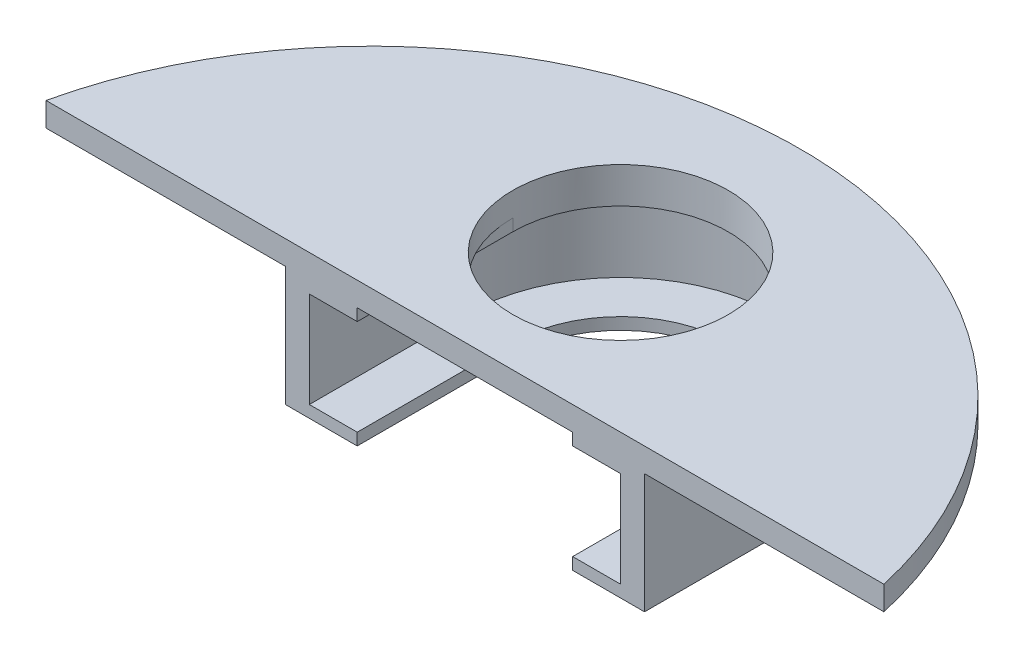
from build123d import *

# Parameters (mm, degrees)
SKETCH1_R           = 9
BOSS_EXTRUDE1_DEPTH = 2
BOSS_EXTRUDE3_DEPTH = 9
BOSS_EXTRUDE4_DEPTH = 1
BOSS_EXTRUDE5_START = -9
BOSS_EXTRUDE5_DEPTH = 1


with BuildPart() as part:
    # Sketch1 → Boss-Extrude1 (new body)
    with BuildSketch(Plane(origin=(0, 0, 0), x_dir=(1, 0, 0), z_dir=(0, 1, 0))):
        with BuildLine():
            Line((-35, -13), (35, -13))
            ThreePointArc((35, -13), (0, 15), (-35, -13))
        make_face()
        Circle(SKETCH1_R, mode=Mode.SUBTRACT)
    extrude(amount=BOSS_EXTRUDE1_DEPTH)

    # Sketch1_5 → Boss-Extrude3 (add)
    with BuildSketch(Plane(origin=(0, 0, 0), x_dir=(1, 0, 0), z_dir=(0, 1, 0))):
        with BuildLine():
            ThreePointArc((9.437961603, 11.658682635), (4.766399393, 12.662994302), (6.3e-08, 13))
            ThreePointArc((6.3e-08, 13), (9.192388178, 9.192388133), (13, 0))
            Line((13, 0), (13, -13))
            Line((13, -13), (15, -13))
            Line((15, -13), (15, 0))
            ThreePointArc((15, 0), (13.538268428, 6.458737336), (9.437961603, 11.658682635))
        make_face()
        with BuildLine():
            ThreePointArc((-9.437961603, 11.658682635), (-4.76639933, 12.662994311), (6.3e-08, 13))
            ThreePointArc((6.3e-08, 13), (4.766399393, 12.662994302), (9.437961603, 11.658682635))
            ThreePointArc((9.437961603, 11.658682635), (5.005984494, 14.140018361), (1.09e-07, 15))
            ThreePointArc((1.09e-07, 15), (-5.005984391, 14.140018397), (-9.437961603, 11.658682635))
        make_face()
        with BuildLine():
            Line((-13, -13), (-13, 0))
            ThreePointArc((-13, 0), (-9.192388133, 9.192388178), (6.3e-08, 13))
            ThreePointArc((6.3e-08, 13), (-4.76639933, 12.662994311), (-9.437961603, 11.658682635))
            ThreePointArc((-9.437961603, 11.658682635), (-13.538268428, 6.458737336), (-15, 0))
            Line((-15, 0), (-15, -13))
            Line((-15, -13), (-13, -13))
        make_face()
    extrude(amount=-BOSS_EXTRUDE3_DEPTH)

    # Sketch1_6 → Boss-Extrude4 (add)
    with BuildSketch(Plane(origin=(0, 0, 0), x_dir=(1, 0, 0), z_dir=(0, 1, 0))):
        with BuildLine():
            ThreePointArc((6.3e-08, 13), (-9.192388133, 9.192388178), (-13, 0))
            Line((-13, 0), (-13, -13))
            Line((-13, -13), (-9, -13))
            Line((-9, -13), (-9, 0))
            ThreePointArc((-9, 0), (0, 9), (9, 0))
            Line((9, 0), (9, -13))
            Line((9, -13), (13, -13))
            Line((13, -13), (13, 0))
            ThreePointArc((13, 0), (9.192388178, 9.192388133), (6.3e-08, 13))
        make_face()
    extrude(amount=-BOSS_EXTRUDE4_DEPTH)

    # Sketch1_7 → Boss-Extrude5 (add)
    with BuildSketch(Plane(origin=(0, 0, 0), x_dir=(1, 0, 0), z_dir=(0, 1, 0)).offset(BOSS_EXTRUDE5_START)):
        with BuildLine():
            Line((-13, -13), (-13, 0))
            ThreePointArc((-13, 0), (-9.192388133, 9.192388178), (6.3e-08, 13))
            ThreePointArc((6.3e-08, 13), (-4.76639933, 12.662994311), (-9.437961603, 11.658682635))
            ThreePointArc((-9.437961603, 11.658682635), (-13.538268428, 6.458737336), (-15, 0))
            Line((-15, 0), (-15, -13))
            Line((-15, -13), (-13, -13))
        make_face()
        with BuildLine():
            ThreePointArc((-9.437961603, 11.658682635), (-4.76639933, 12.662994311), (6.3e-08, 13))
            ThreePointArc((6.3e-08, 13), (4.766399393, 12.662994302), (9.437961603, 11.658682635))
            ThreePointArc((9.437961603, 11.658682635), (5.005984494, 14.140018361), (1.09e-07, 15))
            ThreePointArc((1.09e-07, 15), (-5.005984391, 14.140018397), (-9.437961603, 11.658682635))
        make_face()
        with BuildLine():
            ThreePointArc((9.437961603, 11.658682635), (4.766399393, 12.662994302), (6.3e-08, 13))
            ThreePointArc((6.3e-08, 13), (9.192388178, 9.192388133), (13, 0))
            Line((13, 0), (13, -13))
            Line((13, -13), (15, -13))
            Line((15, -13), (15, 0))
            ThreePointArc((15, 0), (13.538268428, 6.458737336), (9.437961603, 11.658682635))
        make_face()
        with BuildLine():
            ThreePointArc((6.3e-08, 13), (-9.192388133, 9.192388178), (-13, 0))
            Line((-13, 0), (-13, -13))
            Line((-13, -13), (-9, -13))
            Line((-9, -13), (-9, 0))
            ThreePointArc((-9, 0), (0, 9), (9, 0))
            Line((9, 0), (9, -13))
            Line((9, -13), (13, -13))
            Line((13, -13), (13, 0))
            ThreePointArc((13, 0), (9.192388178, 9.192388133), (6.3e-08, 13))
        make_face()
    extrude(amount=-BOSS_EXTRUDE5_DEPTH)


solid = part.part
